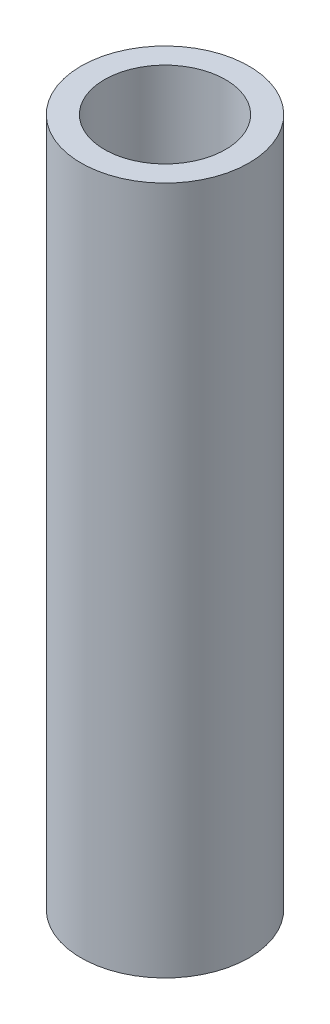
from build123d import *

# Parameters (mm, degrees)
SKETCH1_W = 4.25
SKETCH1_H = 125


with BuildPart() as part:
    # Sketch1 → Revolve1 (revolve)
    with BuildSketch(Plane.XY):
        with Locations((-13.125, 0)):
            Rectangle(SKETCH1_W, SKETCH1_H)
    revolve(axis=Axis((0, 83.183453237, 0), (0, -1, 0)))


solid = part.part
